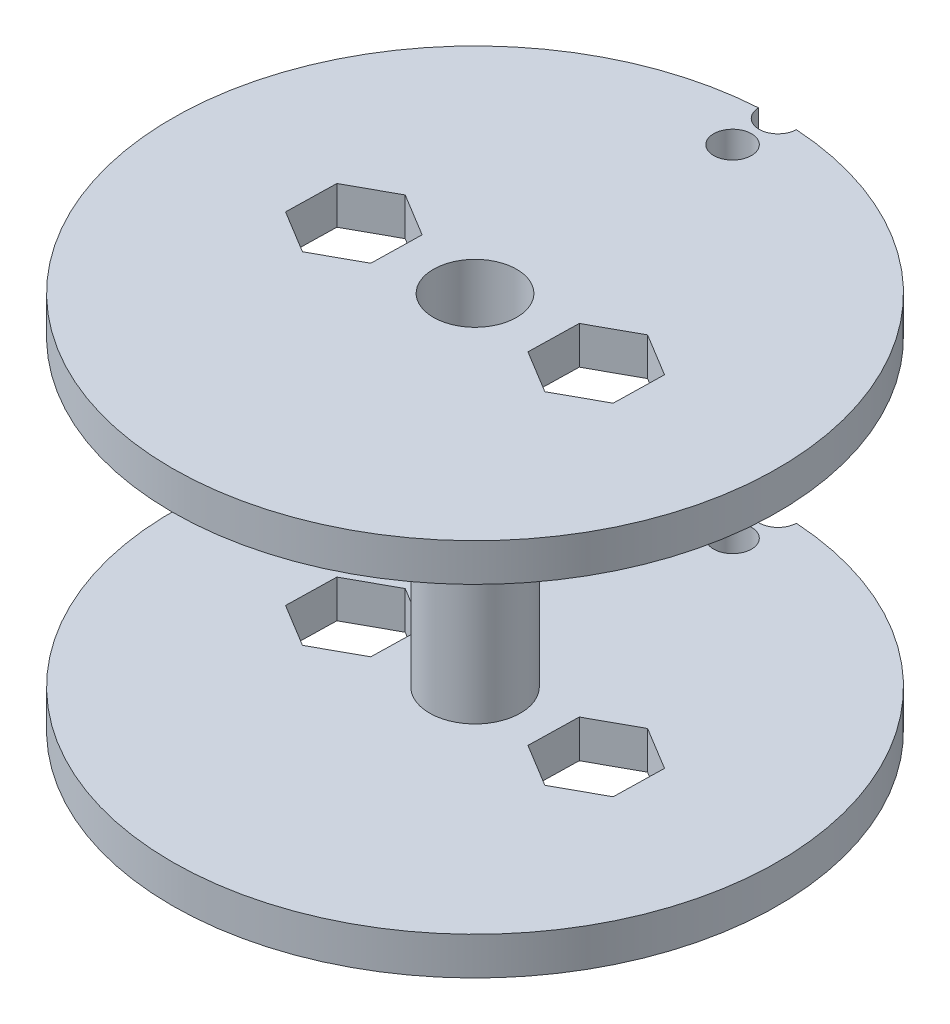
from build123d import *

# Parameters (mm, degrees)
SKETCH1_R           = 20
SKETCH1_R_2         = 2.75
BOSS_EXTRUDE1_DEPTH = 2.5
CUT_EXTRUDE3_DEPTH  = 2.5
SKETCH4_R           = 1.25
CUT_EXTRUDE4_DEPTH  = 5
SKETCH2_R           = 3
SKETCH2_R_2         = 2.75
BOSS_EXTRUDE2_DEPTH = 10


with BuildPart() as part:
    # Sketch1 → Boss-Extrude1 (new body)
    with BuildSketch(Plane(origin=(0, 0, 0), x_dir=(1, 0, 0), z_dir=(0, 1, 0))):
        Circle(SKETCH1_R)
        Circle(SKETCH1_R_2, mode=Mode.SUBTRACT)
    extrude(amount=BOSS_EXTRUDE1_DEPTH)

    # Sketch3 → Cut-Extrude3 (cut)
    with BuildSketch(Plane.XZ):
        Polygon((-5.161329605, 1.721273866), (-8.071331697, 3.318997608), (-10.910002092, 1.597723742), (-10.838670395, -1.721273866), (-7.928668303, -3.318997608), (-5.089997908, -1.597723742), align=None)
        Polygon((5.161329605, -1.721273866), (8.071331697, -3.318997608), (10.910002092, -1.597723742), (10.838670395, 1.721273866), (7.928668303, 3.318997608), (5.089997908, 1.597723742), align=None)
    extrude(amount=-CUT_EXTRUDE3_DEPTH, mode=Mode.SUBTRACT)

    # Sketch4 → Cut-Extrude4 (cut)
    with BuildSketch(Plane(origin=(0, 2.5, 0), x_dir=(1, 0, 0), z_dir=(0, 1, 0))):
        with Locations((0, 17)):
            Circle(SKETCH4_R)
        with Locations((0, 20)):
            Circle(SKETCH4_R)
    extrude(amount=-CUT_EXTRUDE4_DEPTH, mode=Mode.SUBTRACT)

    # Sketch2 → Boss-Extrude2 (add)
    with BuildSketch(Plane(origin=(0, 2.5, 0), x_dir=(1, 0, 0), z_dir=(0, 1, 0))):
        Circle(SKETCH2_R)
        Circle(SKETCH2_R_2, mode=Mode.SUBTRACT)
    extrude(amount=BOSS_EXTRUDE2_DEPTH)

    # Mirror7: part across plane


with BuildPart() as part_1:
    add(part.part)
    add(part.part.mirror(Plane.ZX.offset(12.5)))


solid = part_1.part
